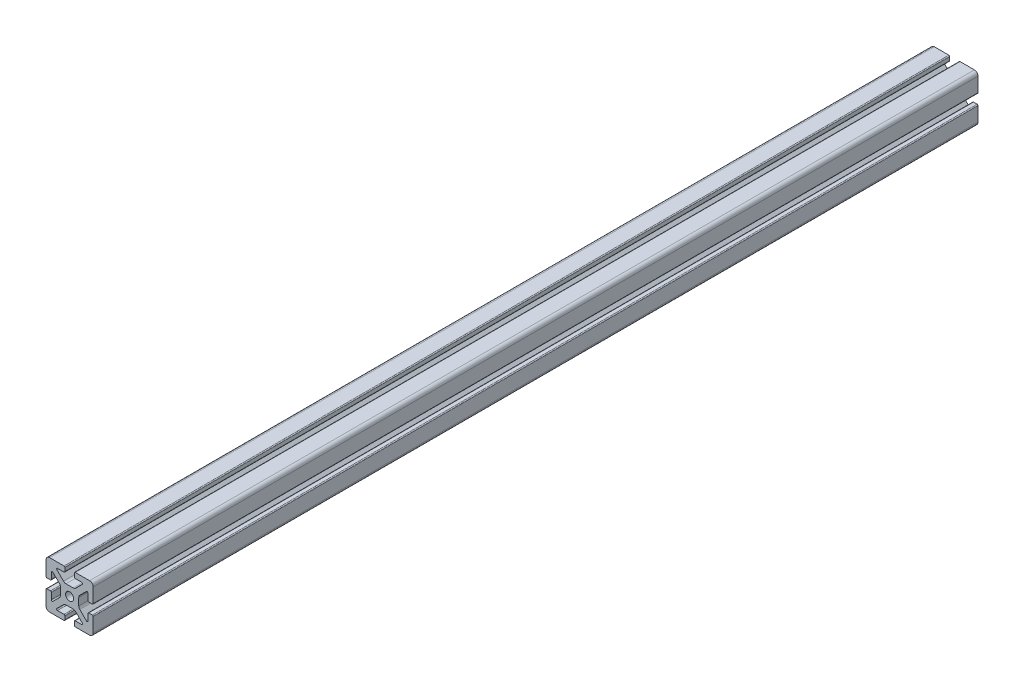
from build123d import *

# Parameters (mm, degrees)
SKETCH1_R           = 3.4036
BOSS_EXTRUDE1_DEPTH = 375


with BuildPart() as part:
    # Sketch1 → Boss-Extrude1 (new body, symmetric)
    with BuildSketch(Plane.XY):
        with BuildLine():
            Line((-20, 16.952), (-20, 4.7625))
            ThreePointArc((-20, 4.7625), (-19.776815367, 4.223684633), (-19.238, 4.0005))
            Line((-19.238, 4.0005), (-16.2662, 4.0005))
            ThreePointArc((-16.2662, 4.0005), (-15.727384633, 4.223684633), (-15.5042, 4.7625))
            Line((-15.5042, 4.7625), (-15.5042, 10.2235))
            ThreePointArc((-15.5042, 10.2235), (-15.033804775, 10.927496204), (-14.203384633, 10.762315367))
            Line((-14.203384633, 10.762315367), (-8.635059555, 5.19399029))
            ThreePointArc((-8.635059555, 5.19399029), (-7.985348265, 4.221628629), (-7.7572, 3.074649845))
            Line((-7.7572, 3.074649845), (-7.7572, -3.074649845))
            ThreePointArc((-7.7572, -3.074649845), (-7.985348265, -4.221628629), (-8.635059555, -5.19399029))
            Line((-8.635059555, -5.19399029), (-14.203384633, -10.762315367))
            ThreePointArc((-14.203384633, -10.762315367), (-15.033804775, -10.927496204), (-15.5042, -10.2235))
            Line((-15.5042, -10.2235), (-15.5042, -4.7625))
            ThreePointArc((-15.5042, -4.7625), (-15.727384633, -4.223684633), (-16.2662, -4.0005))
            Line((-16.2662, -4.0005), (-19.238, -4.0005))
            ThreePointArc((-19.238, -4.0005), (-19.776815367, -4.223684633), (-20, -4.7625))
            Line((-20, -4.7625), (-20, -16.952))
            ThreePointArc((-20, -16.952), (-19.107261469, -19.107261469), (-16.952, -20))
            Line((-16.952, -20), (-4.7625, -20))
            ThreePointArc((-4.7625, -20), (-4.223684633, -19.776815367), (-4.0005, -19.238))
            Line((-4.0005, -19.238), (-4.0005, -16.2662))
            ThreePointArc((-4.0005, -16.2662), (-4.223684633, -15.727384633), (-4.7625, -15.5042))
            Line((-4.7625, -15.5042), (-10.2235, -15.5042))
            ThreePointArc((-10.2235, -15.5042), (-10.927496204, -15.033804775), (-10.762315367, -14.203384633))
            Line((-10.762315367, -14.203384633), (-5.19399029, -8.635059555))
            ThreePointArc((-5.19399029, -8.635059555), (-4.221628629, -7.985348265), (-3.074649845, -7.7572))
            Line((-3.074649845, -7.7572), (3.074649845, -7.7572))
            ThreePointArc((3.074649845, -7.7572), (4.221628629, -7.985348265), (5.19399029, -8.635059555))
            Line((5.19399029, -8.635059555), (10.762315367, -14.203384633))
            ThreePointArc((10.762315367, -14.203384633), (10.927496204, -15.033804775), (10.2235, -15.5042))
            Line((10.2235, -15.5042), (4.7625, -15.5042))
            ThreePointArc((4.7625, -15.5042), (4.223684633, -15.727384633), (4.0005, -16.2662))
            Line((4.0005, -16.2662), (4.0005, -19.238))
            ThreePointArc((4.0005, -19.238), (4.223684633, -19.776815367), (4.7625, -20))
            Line((4.7625, -20), (16.952, -20))
            ThreePointArc((16.952, -20), (19.107261469, -19.107261469), (20, -16.952))
            Line((20, -16.952), (20, -4.7625))
            ThreePointArc((20, -4.7625), (19.776815367, -4.223684633), (19.238, -4.0005))
            Line((19.238, -4.0005), (16.2662, -4.0005))
            ThreePointArc((16.2662, -4.0005), (15.727384633, -4.223684633), (15.5042, -4.7625))
            Line((15.5042, -4.7625), (15.5042, -10.2235))
            ThreePointArc((15.5042, -10.2235), (15.033804775, -10.927496204), (14.203384633, -10.762315367))
            Line((14.203384633, -10.762315367), (8.635059555, -5.19399029))
            ThreePointArc((8.635059555, -5.19399029), (7.985348265, -4.221628629), (7.7572, -3.074649845))
            Line((7.7572, -3.074649845), (7.7572, 3.074649845))
            ThreePointArc((7.7572, 3.074649845), (7.985348265, 4.221628629), (8.635059555, 5.19399029))
            Line((8.635059555, 5.19399029), (14.203384633, 10.762315367))
            ThreePointArc((14.203384633, 10.762315367), (15.033804775, 10.927496204), (15.5042, 10.2235))
            Line((15.5042, 10.2235), (15.5042, 4.7625))
            ThreePointArc((15.5042, 4.7625), (15.727384633, 4.223684633), (16.2662, 4.0005))
            Line((16.2662, 4.0005), (19.238, 4.0005))
            ThreePointArc((19.238, 4.0005), (19.776815367, 4.223684633), (20, 4.7625))
            Line((20, 4.7625), (20, 16.952))
            ThreePointArc((20, 16.952), (19.107261469, 19.107261469), (16.952, 20))
            Line((16.952, 20), (4.7625, 20))
            ThreePointArc((4.7625, 20), (4.223684633, 19.776815367), (4.0005, 19.238))
            Line((4.0005, 19.238), (4.0005, 16.2662))
            ThreePointArc((4.0005, 16.2662), (4.223684633, 15.727384633), (4.7625, 15.5042))
            Line((4.7625, 15.5042), (10.2235, 15.5042))
            ThreePointArc((10.2235, 15.5042), (10.927496204, 15.033804775), (10.762315367, 14.203384633))
            Line((10.762315367, 14.203384633), (5.19399029, 8.635059555))
            ThreePointArc((5.19399029, 8.635059555), (4.221628629, 7.985348265), (3.074649845, 7.7572))
            Line((3.074649845, 7.7572), (-3.074649845, 7.7572))
            ThreePointArc((-3.074649845, 7.7572), (-4.221628629, 7.985348265), (-5.19399029, 8.635059555))
            Line((-5.19399029, 8.635059555), (-10.762315367, 14.203384633))
            ThreePointArc((-10.762315367, 14.203384633), (-10.927496204, 15.033804775), (-10.2235, 15.5042))
            Line((-10.2235, 15.5042), (-4.7625, 15.5042))
            ThreePointArc((-4.7625, 15.5042), (-4.223684633, 15.727384633), (-4.0005, 16.2662))
            Line((-4.0005, 16.2662), (-4.0005, 19.238))
            ThreePointArc((-4.0005, 19.238), (-4.223684633, 19.776815367), (-4.7625, 20))
            Line((-4.7625, 20), (-16.952, 20))
            ThreePointArc((-16.952, 20), (-19.107261469, 19.107261469), (-20, 16.952))
        make_face()
        Circle(SKETCH1_R, mode=Mode.SUBTRACT)
    extrude(amount=BOSS_EXTRUDE1_DEPTH, both=True)


solid = part.part
